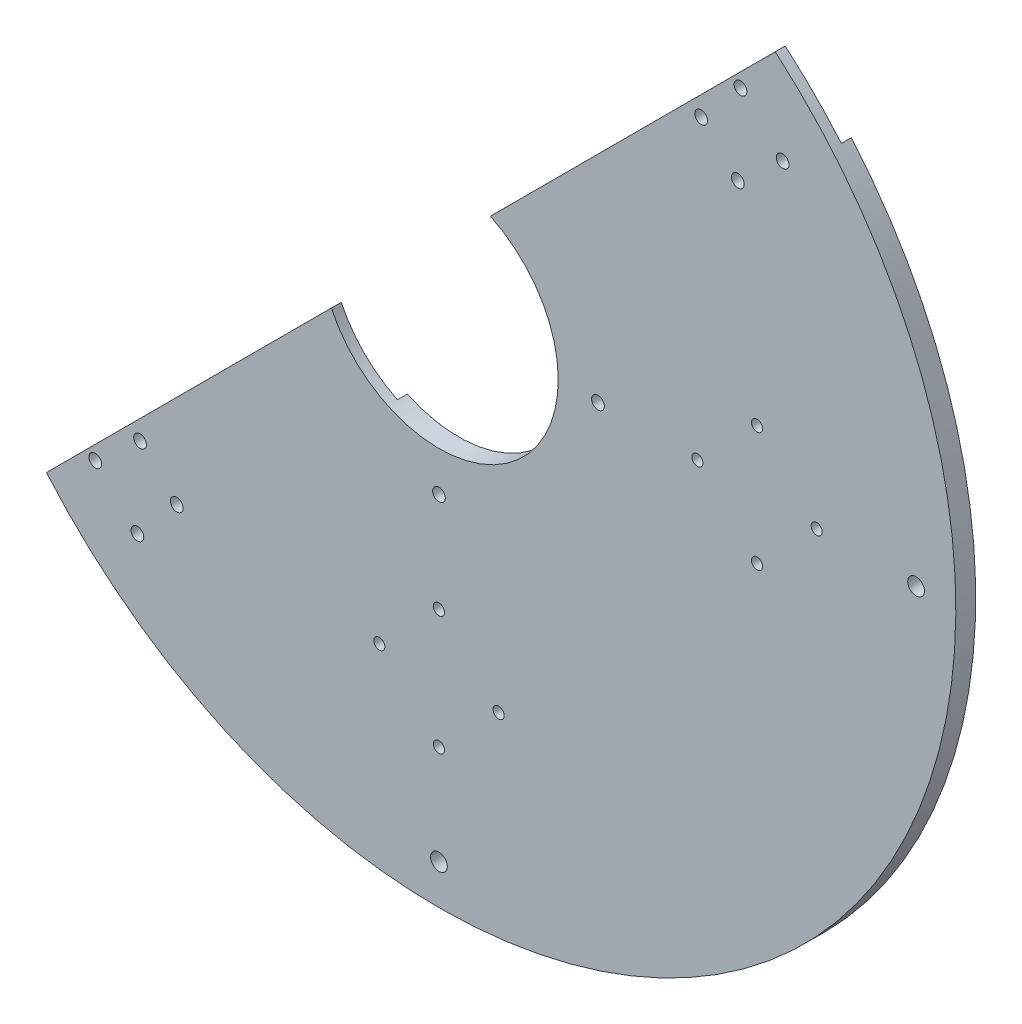
from build123d import *

# Parameters (mm, degrees)
SKETCH_1_R               = 130
SKETCH_1_R_2             = 30
SKETCH_1_R_3             = 2.1
SKETCH_1_R_4             = 1.6
EXTRUDE_1_DEPTH          = 5
SKETCH_2_R               = 1.4
CUT_EXTRUDE_1_DEPTH      = 1
CUT_EXTRUDE_1_DEPTH_BACK = 6
CUT_EXTRUDE_2_REACH      = 7
SKETCH_8_R               = 1.6
CUT_EXTRUDE_3_DEPTH      = 314.847763109


with BuildPart() as part:
    # 草图1 → 凸台-拉伸1 (new body)
    with BuildSketch(Plane.XY):
        Circle(SKETCH_1_R)
        Circle(SKETCH_1_R_2, mode=Mode.SUBTRACT)
        with Locations((0, 120)):
            Circle(SKETCH_1_R_3, mode=Mode.SUBTRACT)
        with Locations((120, 0)):
            Circle(SKETCH_1_R_3, mode=Mode.SUBTRACT)
        with Locations((0, -120)):
            Circle(SKETCH_1_R_3, mode=Mode.SUBTRACT)
        with Locations((-120, 0)):
            Circle(SKETCH_1_R_3, mode=Mode.SUBTRACT)
        with Locations((0, 40)):
            Circle(SKETCH_1_R_4, mode=Mode.SUBTRACT)
        with Locations((40, 0)):
            Circle(SKETCH_1_R_4, mode=Mode.SUBTRACT)
        with Locations((0, -40)):
            Circle(SKETCH_1_R_4, mode=Mode.SUBTRACT)
        with Locations((-40, 0)):
            Circle(SKETCH_1_R_4, mode=Mode.SUBTRACT)
    extrude(amount=EXTRUDE_1_DEPTH)

    # 草图2 → 切除-拉伸1 (cut, two sides)
    with BuildSketch(Plane.XY.offset(5)) as cut_extrude_1_sk:
        with Locations((0, 95)):
            Circle(SKETCH_2_R)
        with Locations((15, 80)):
            Circle(SKETCH_2_R)
        with Locations((0, 65)):
            Circle(SKETCH_2_R)
        with Locations((-15, 80)):
            Circle(SKETCH_2_R)
        with Locations((95, 0)):
            Circle(SKETCH_2_R)
        with Locations((80, -15)):
            Circle(SKETCH_2_R)
        with Locations((65, 0)):
            Circle(SKETCH_2_R)
        with Locations((80, 15)):
            Circle(SKETCH_2_R)
        with Locations((0, -95)):
            Circle(SKETCH_2_R)
        with Locations((-15, -80)):
            Circle(SKETCH_2_R)
        with Locations((0, -65)):
            Circle(SKETCH_2_R)
        with Locations((15, -80)):
            Circle(SKETCH_2_R)
        with Locations((-95, 0)):
            Circle(SKETCH_2_R)
        with Locations((-80, 15)):
            Circle(SKETCH_2_R)
        with Locations((-65, 0)):
            Circle(SKETCH_2_R)
        with Locations((-80, -15)):
            Circle(SKETCH_2_R)
    extrude(amount=CUT_EXTRUDE_1_DEPTH, mode=Mode.SUBTRACT)
    extrude(cut_extrude_1_sk.sketch, amount=-CUT_EXTRUDE_1_DEPTH_BACK, mode=Mode.SUBTRACT)

    # 草图8 → 切除-拉伸2 (cut, up to next)
    with BuildSketch(Plane(origin=(0, 0, 0), x_dir=(-1, 0, 0), z_dir=(0, 0, -1)), mode=Mode.PRIVATE) as cut_extrude_2_sk1:
        with Locations((-75.840860977, 86.447462694)):
            Circle(SKETCH_8_R)
    cut_extrude_2_tool1 = extrude(cut_extrude_2_sk1.sketch, amount=-CUT_EXTRUDE_2_REACH, mode=Mode.PRIVATE) & part.part
    add(cut_extrude_2_tool1.solids().sort_by_distance((75.840861, 86.447463, 0))[0], mode=Mode.SUBTRACT)
    # 草图8 → 切除-拉伸2 (cut, up to next)
    with BuildSketch(Plane(origin=(0, 0, 0), x_dir=(-1, 0, 0), z_dir=(0, 0, -1)), mode=Mode.PRIVATE) as cut_extrude_2_sk2:
        with Locations((-86.447462694, 75.840860977)):
            Circle(SKETCH_8_R)
    cut_extrude_2_tool2 = extrude(cut_extrude_2_sk2.sketch, amount=-CUT_EXTRUDE_2_REACH, mode=Mode.PRIVATE) & part.part
    add(cut_extrude_2_tool2.solids().sort_by_distance((86.447463, 75.840861, 0))[0], mode=Mode.SUBTRACT)
    # 草图8 → 切除-拉伸2 (cut, up to next)
    with BuildSketch(Plane(origin=(0, 0, 0), x_dir=(-1, 0, 0), z_dir=(0, 0, -1)), mode=Mode.PRIVATE) as cut_extrude_2_sk3:
        with Locations((-65.948574762, 75.171706691)):
            Circle(SKETCH_8_R)
    cut_extrude_2_tool3 = extrude(cut_extrude_2_sk3.sketch, amount=-CUT_EXTRUDE_2_REACH, mode=Mode.PRIVATE) & part.part
    add(cut_extrude_2_tool3.solids().sort_by_distance((65.948575, 75.171707, 0))[0], mode=Mode.SUBTRACT)
    # 草图8 → 切除-拉伸2 (cut, up to next)
    with BuildSketch(Plane(origin=(0, 0, 0), x_dir=(-1, 0, 0), z_dir=(0, 0, -1)), mode=Mode.PRIVATE) as cut_extrude_2_sk4:
        with Locations((-75.171706691, 65.948574762)):
            Circle(SKETCH_8_R)
    cut_extrude_2_tool4 = extrude(cut_extrude_2_sk4.sketch, amount=-CUT_EXTRUDE_2_REACH, mode=Mode.PRIVATE) & part.part
    add(cut_extrude_2_tool4.solids().sort_by_distance((75.171707, 65.948575, 0))[0], mode=Mode.SUBTRACT)
    # 草图8 → 切除-拉伸2 (cut, up to next)
    with BuildSketch(Plane(origin=(0, 0, 0), x_dir=(-1, 0, 0), z_dir=(0, 0, -1)), mode=Mode.PRIVATE) as cut_extrude_2_sk5:
        with Locations((65.948574762, -75.171706691)):
            Circle(SKETCH_8_R)
    cut_extrude_2_tool5 = extrude(cut_extrude_2_sk5.sketch, amount=-CUT_EXTRUDE_2_REACH, mode=Mode.PRIVATE) & part.part
    add(cut_extrude_2_tool5.solids().sort_by_distance((-65.948575, -75.171707, 0))[0], mode=Mode.SUBTRACT)
    # 草图8 → 切除-拉伸2 (cut, up to next)
    with BuildSketch(Plane(origin=(0, 0, 0), x_dir=(-1, 0, 0), z_dir=(0, 0, -1)), mode=Mode.PRIVATE) as cut_extrude_2_sk6:
        with Locations((75.171706691, -65.948574762)):
            Circle(SKETCH_8_R)
    cut_extrude_2_tool6 = extrude(cut_extrude_2_sk6.sketch, amount=-CUT_EXTRUDE_2_REACH, mode=Mode.PRIVATE) & part.part
    add(cut_extrude_2_tool6.solids().sort_by_distance((-75.171707, -65.948575, 0))[0], mode=Mode.SUBTRACT)
    # 草图8 → 切除-拉伸2 (cut, up to next)
    with BuildSketch(Plane(origin=(0, 0, 0), x_dir=(-1, 0, 0), z_dir=(0, 0, -1)), mode=Mode.PRIVATE) as cut_extrude_2_sk7:
        with Locations((75.840860977, -86.447462694)):
            Circle(SKETCH_8_R)
    cut_extrude_2_tool7 = extrude(cut_extrude_2_sk7.sketch, amount=-CUT_EXTRUDE_2_REACH, mode=Mode.PRIVATE) & part.part
    add(cut_extrude_2_tool7.solids().sort_by_distance((-75.840861, -86.447463, 0))[0], mode=Mode.SUBTRACT)
    # 草图8 → 切除-拉伸2 (cut, up to next)
    with BuildSketch(Plane(origin=(0, 0, 0), x_dir=(-1, 0, 0), z_dir=(0, 0, -1)), mode=Mode.PRIVATE) as cut_extrude_2_sk8:
        with Locations((86.447462694, -75.840860977)):
            Circle(SKETCH_8_R)
    cut_extrude_2_tool8 = extrude(cut_extrude_2_sk8.sketch, amount=-CUT_EXTRUDE_2_REACH, mode=Mode.PRIVATE) & part.part
    add(cut_extrude_2_tool8.solids().sort_by_distance((-86.447463, -75.840861, 0))[0], mode=Mode.SUBTRACT)

    # 草图5 → 切除-拉伸3 (cut, through all)
    with BuildSketch(Plane(origin=(91.923881554, 91.923881554, 0), x_dir=(0, 0, -1), z_dir=(0.707106781, 0.707106781, 0))):
        Polygon((0, -10), (-2.5, -10), (-2.5, 10), (-5, 10), (-5, 130), (0, 130), align=None)
    extrude(amount=-CUT_EXTRUDE_3_DEPTH, mode=Mode.SUBTRACT)


solid = part.part
